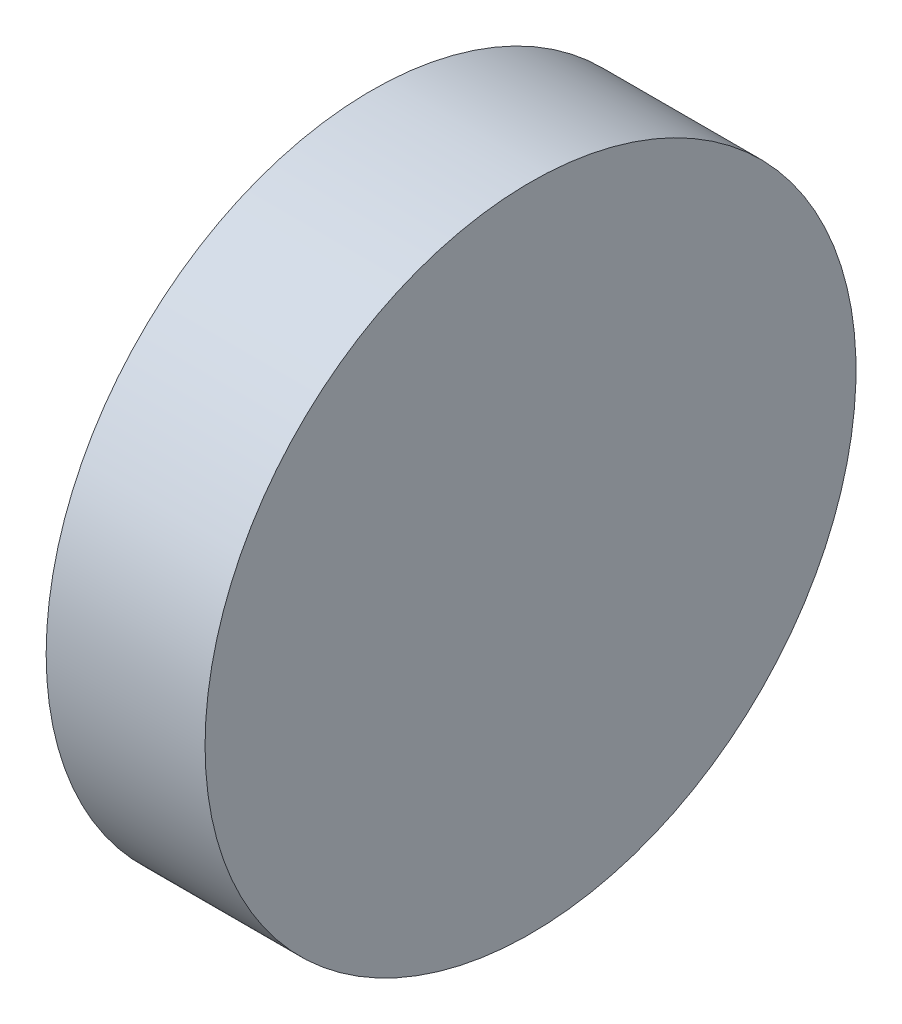
from build123d import *

# Parameters (mm, degrees)
SKETCH_1_W = 3.1
SKETCH_1_H = 6.35


with BuildPart() as part:
    # 草图1 → 旋转1 (revolve)
    with BuildSketch(Plane.XY, mode=Mode.PRIVATE) as revolve_1_sk:
        with Locations((261.274352893, 86.818179349)):
            Rectangle(SKETCH_1_W, SKETCH_1_H)
    revolve(revolve_1_sk.sketch.rotate(Axis((254.000801993, 83.643179349, 0), (1, 0, 0)), 90), axis=Axis((254.000801993, 83.643179349, 0), (1, 0, 0)))  # turned: the seam where the file's is


solid = part.part
